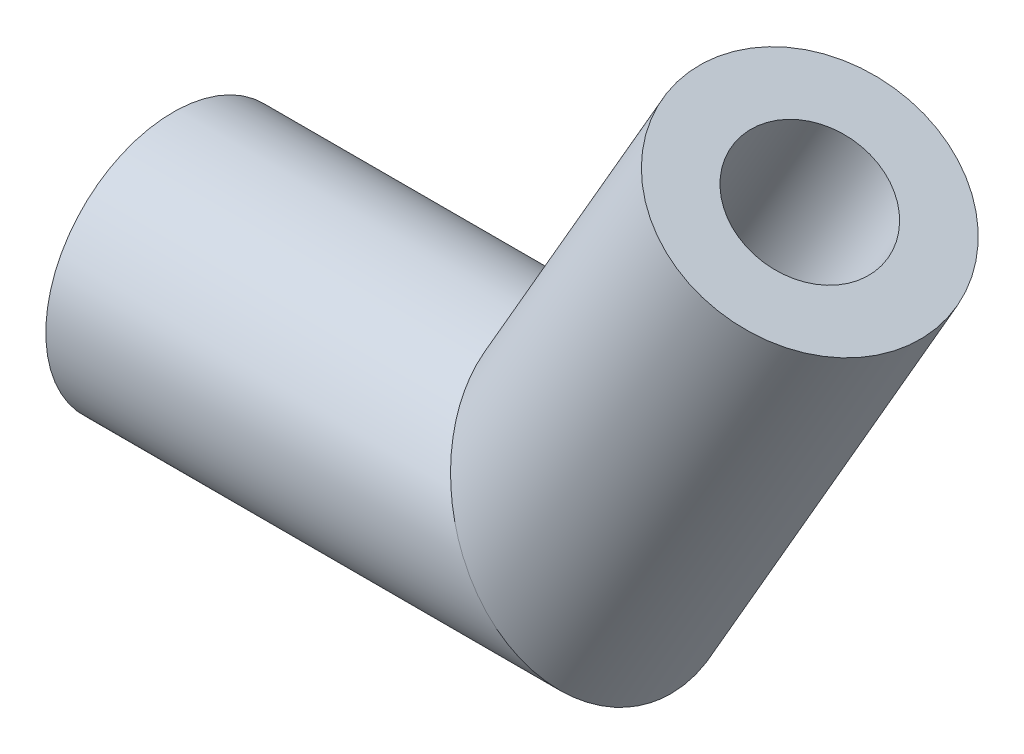
from build123d import *

# Parameters (mm, degrees)
SKETCH3_R   = 3
SKETCH3_R_2 = 1.6


with BuildPart() as part:
    # Sweep1: sweep along a path in Sketch2
    with BuildLine(Plane.XY) as sweep1_path:
        Line((0, 0), (10, 0))
        Line((10, 0), (15, 8.660254038))
    # Sketch3 → Sweep1 (sweep)
    with BuildSketch(Plane(origin=(0, 0, 0), x_dir=(0, 0, -1), z_dir=(1, 0, 0))):
        Circle(SKETCH3_R)
        Circle(SKETCH3_R_2, mode=Mode.SUBTRACT)
    sweep(path=sweep1_path.line, transition=Transition.RIGHT)


solid = part.part
